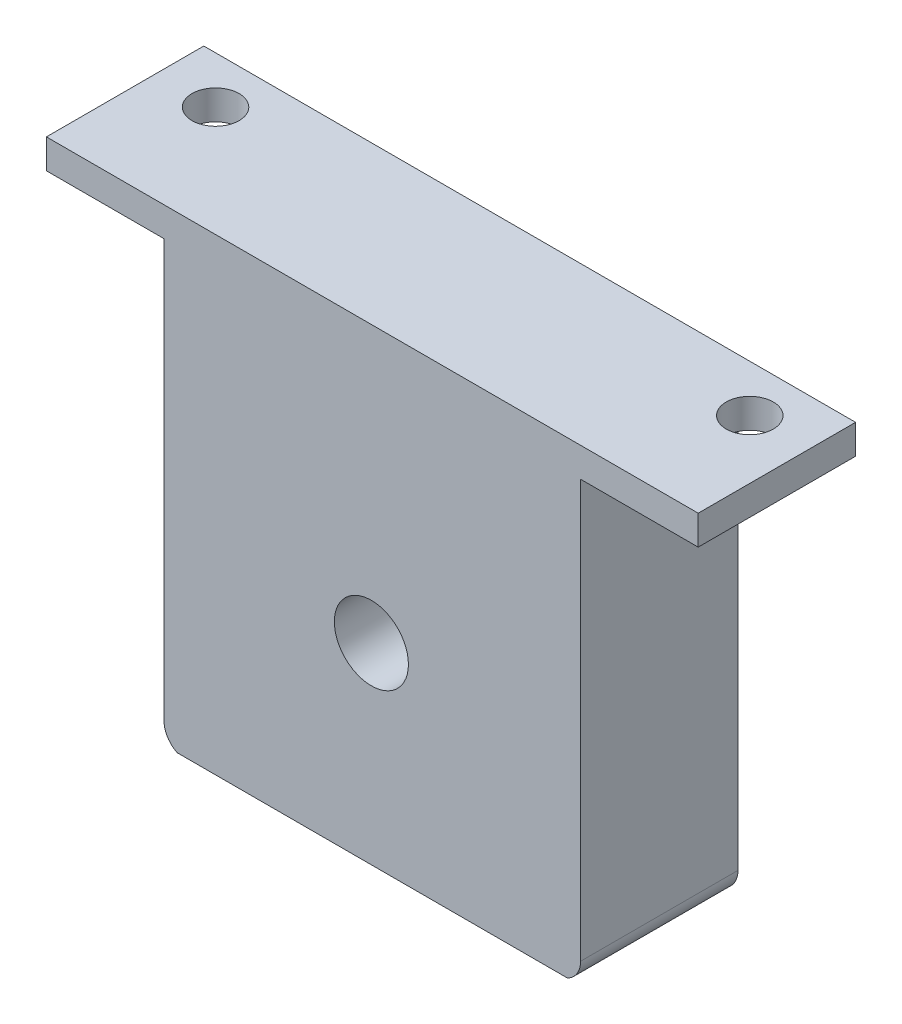
from build123d import *

# Parameters (mm, degrees)
SKETCH1_W           = 45
SKETCH1_H           = 50.8
SKETCH1_R           = 4
BOSS_EXTRUDE1_DEPTH = 17
FILLET1_R           = 2.54
SKETCH3_W           = 17
SKETCH3_H           = 0.254
CUT_EXTRUDE2_DEPTH  = 46
SKETCH4_W           = 12.7
SKETCH4_H           = 17
SKETCH4_R           = 2.54
BOSS_EXTRUDE2_DEPTH = 3.175


with BuildPart() as part:
    # Sketch1 → Boss-Extrude1 (new body)
    with BuildSketch(Plane.XY):
        with Locations((22.5, 25.4)):
            Rectangle(SKETCH1_W, SKETCH1_H)
        with Locations((22.4, 21)):
            Circle(SKETCH1_R, mode=Mode.SUBTRACT)
    extrude(amount=BOSS_EXTRUDE1_DEPTH)

    # Fillet1
    fillet1_edges = [part.edges().sort_by_distance(p)[0] for p in [
        (45, 0, 8.5),
        (0, 0, 8.5),
    ]]
    fillet(fillet1_edges, radius=FILLET1_R)

    # Sketch3 → Cut-Extrude2 (cut, through all)
    with BuildSketch(Plane(origin=(45, 0, 0), x_dir=(0, 0, -1), z_dir=(1, 0, 0))):
        with Locations((-8.5, 0.127)):
            Rectangle(SKETCH3_W, SKETCH3_H)
    extrude(amount=-CUT_EXTRUDE2_DEPTH, mode=Mode.SUBTRACT)

    # Sketch4 → Boss-Extrude2 (add)
    with BuildSketch(Plane(origin=(0, 50.8, 0), x_dir=(1, 0, 0), z_dir=(0, 1, 0))):
        with Locations((51.35, -8.5)):
            Rectangle(SKETCH4_W, SKETCH4_H)
        with Locations((51.35, -5.08)):
            Circle(SKETCH4_R, mode=Mode.SUBTRACT)
        with Locations((-6.35, -8.5)):
            Rectangle(SKETCH4_W, SKETCH4_H)
        with Locations((-6.35, -5.08)):
            Circle(SKETCH4_R, mode=Mode.SUBTRACT)
    extrude(amount=-BOSS_EXTRUDE2_DEPTH)


solid = part.part
